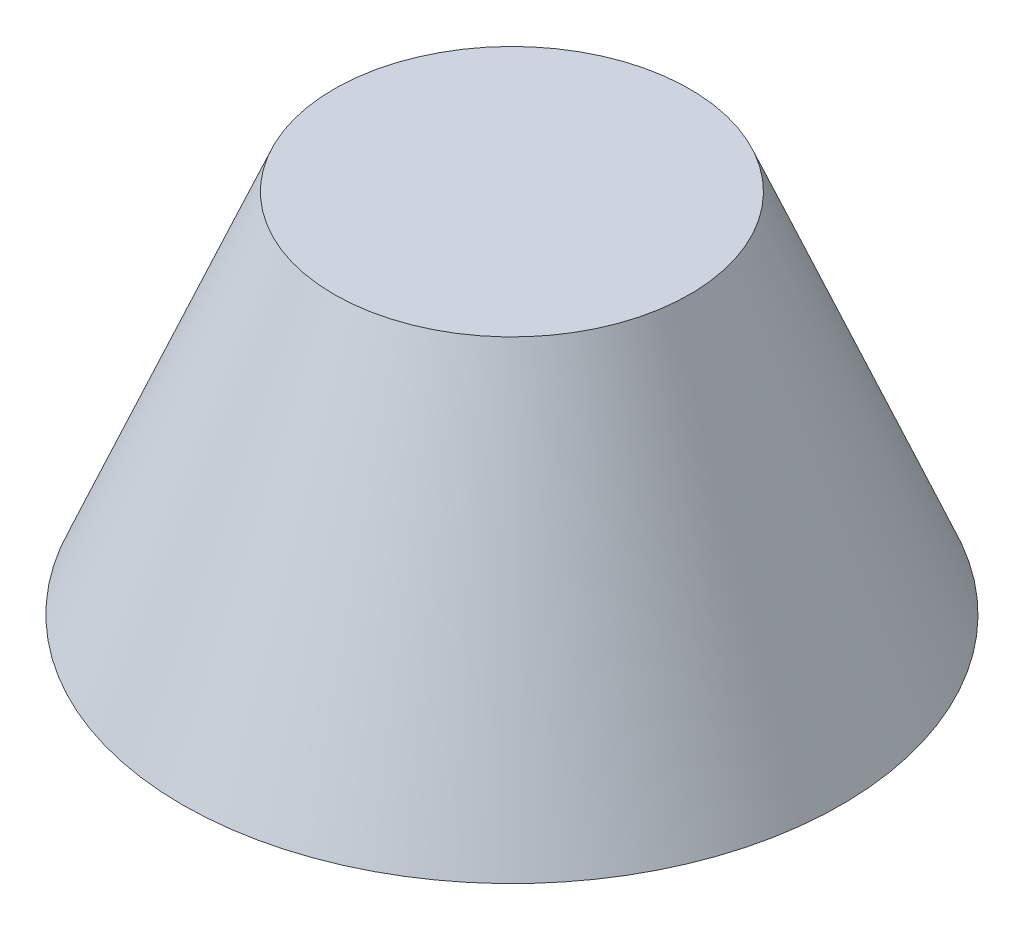
from build123d import *

# Parameters (mm, degrees)
SKETCH_1_R      = 90
EXTRUDE_1_DEPTH = 100
EXTRUDE_1_TAPER = 22.5


with BuildPart() as part:
    # 草图1 → 凸台-拉伸1 (new body)
    with BuildSketch(Plane(origin=(0, 0, 0), x_dir=(1, 0, 0), z_dir=(0, 1, 0))):
        Circle(SKETCH_1_R)
    extrude(amount=EXTRUDE_1_DEPTH, taper=EXTRUDE_1_TAPER)


solid = part.part
